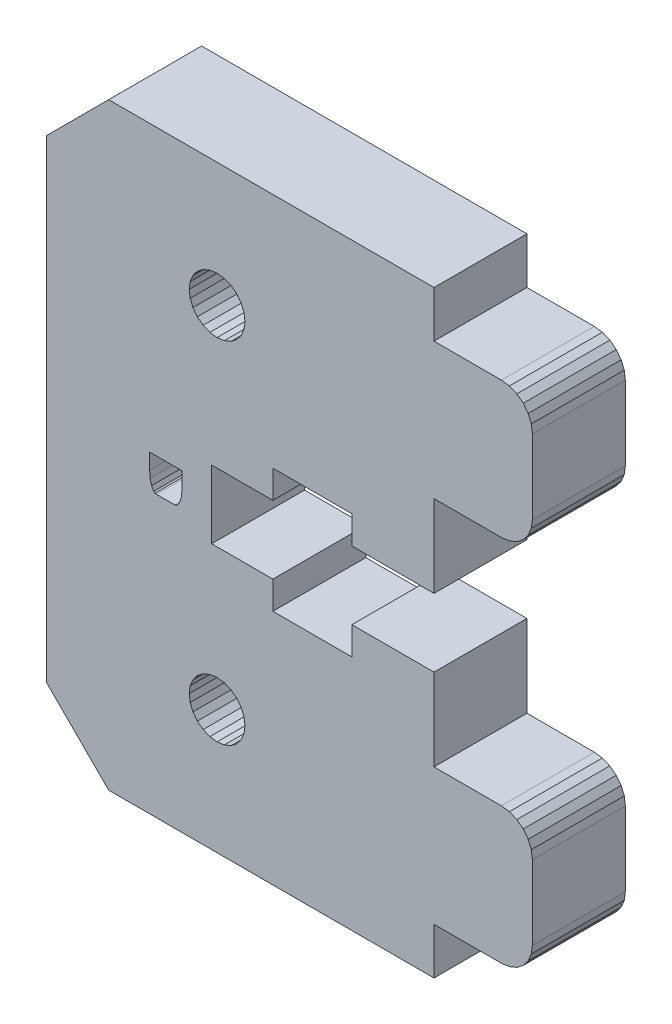
from build123d import *

# Parameters (mm, degrees)
BOSS_EXTRUDE1_DEPTH = 6


with BuildPart() as part:
    # Sketch1 → Boss-Extrude1 (new body)
    with BuildSketch(Plane.XY):
        Polygon((316.255247905, 240.964803396), (315.841034343, 241.282640641), (315.358672433, 241.482441486), (314.841034343, 241.550589833), (310.491036452, 241.550589833), (310.491036452, 246.850587088), (305.19103763, 246.850587088), (305.19103763, 245.050588856), (300.091039865, 245.050588856), (300.091039865, 246.850587088), (296.141040043, 246.850587088), (296.141040043, 251.25059176), (300.091039865, 251.25059176), (300.091039865, 253.050589992), (305.19103763, 253.050589992), (305.19103763, 251.25059176), (310.491036452, 251.25059176), (310.491036452, 256.550583767), (314.841034343, 256.550583767), (315.358672433, 256.618732114), (315.841034343, 256.818532959), (316.255247905, 257.136370204), (316.57308515, 257.550583767), (316.772885995, 258.032945676), (316.841034343, 258.550583767), (316.841034343, 263.350579732), (316.772885995, 263.868217822), (316.57308515, 264.350579732), (316.255247905, 264.764793294), (315.841034343, 265.082630539), (315.358672433, 265.282431384), (314.841034343, 265.350579732), (310.491036452, 265.350579732), (310.491036452, 268.350579732), (289.491036452, 268.350579732), (285.491036452, 264.350579732), (285.491036452, 233.750595391), (289.491036452, 229.750595391), (310.491036452, 229.750595391), (310.491036452, 232.750595391), (314.841034343, 232.750595391), (315.358672433, 232.818743738), (315.841034343, 233.018544583), (316.255247905, 233.336381829), (316.57308515, 233.750595391), (316.772885995, 234.232957301), (316.841034343, 234.750595391), (316.841034343, 239.550589833), (316.772885995, 240.068227923), (316.57308515, 240.550589833), align=None)
        Polygon((296.491036452, 235.950595391), (296.02516217, 236.011928904), (295.591036452, 236.191749664), (295.218244245, 236.477803185), (294.932190725, 236.850595391), (294.752369964, 237.28472111), (294.691036452, 237.750595391), (294.752369964, 238.216469672), (294.932190725, 238.650595391), (295.218244245, 239.023387597), (295.591036452, 239.309441118), (296.02516217, 239.489261878), (296.491036452, 239.550595391), (296.956910733, 239.489261878), (297.391036452, 239.309441118), (297.763828658, 239.023387597), (298.049882178, 238.650595391), (298.229702939, 238.216469672), (298.291036452, 237.750595391), (298.229702939, 237.28472111), (298.049882178, 236.850595391), (297.763828658, 236.477803185), (297.391036452, 236.191749664), (296.956910733, 236.011928904), align=None, mode=Mode.SUBTRACT)
        Polygon((292.167294345, 248.521745899), (292.136860132, 248.95490496), (292.136860132, 249.972673633), (292.137050681, 249.972673633), (294.228561733, 249.972673633), (294.228561733, 248.95490496), (294.193435256, 248.521745899), (294.088055826, 248.158815973), (293.932728797, 247.912954455), (293.84394944, 247.851489075), (293.747759523, 247.831000615), (292.580314782, 247.831000615), (292.58017187, 247.831000615), (292.485290658, 247.851455341), (292.485134177, 247.851489075), (292.399859132, 247.912954455), (292.258596985, 248.158815973), align=None, mode=Mode.SUBTRACT)
        Polygon((295.218244245, 259.077787526), (294.932190725, 259.450579732), (294.752369964, 259.884705451), (294.691036452, 260.350579732), (294.752369964, 260.816454013), (294.932190725, 261.250579732), (295.218244245, 261.623371938), (295.591036452, 261.909425459), (296.02516217, 262.089246219), (296.491036452, 262.150579732), (296.956910733, 262.089246219), (297.391036452, 261.909425459), (297.763828658, 261.623371938), (298.049882178, 261.250579732), (298.229702939, 260.816454013), (298.291036452, 260.350579732), (298.229702939, 259.884705451), (298.049882178, 259.450579732), (297.763828658, 259.077787526), (297.391036452, 258.791734005), (296.956910733, 258.611913244), (296.491036452, 258.550579732), (296.02516217, 258.611913244), (295.591036452, 258.791734005), align=None, mode=Mode.SUBTRACT)
    extrude(amount=BOSS_EXTRUDE1_DEPTH)


solid = part.part
